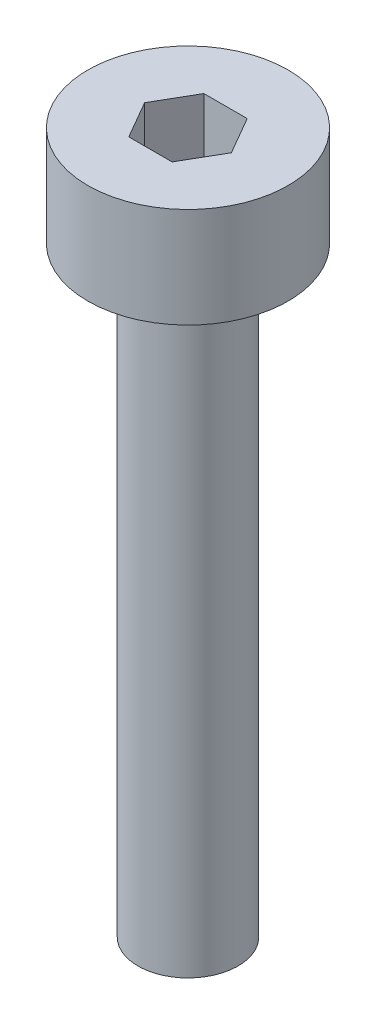
from build123d import *

# Parameters (mm, degrees)
SKETCH_1_R            = 2
EXTRUDE_246_DEPTH     = 2
CUT_EXTRUDE_376_DEPTH = 1.5
SKETCH_3_R            = 1
EXTRUDE_477_DEPTH     = 12


with BuildPart() as part:
    # 草图1 → Extrude 246 (new body)
    with BuildSketch(Plane(origin=(0, 0, 0), x_dir=(1, 0, 0), z_dir=(0, 1, 0))):
        Circle(SKETCH_1_R)
    extrude(amount=EXTRUDE_246_DEPTH)

    # 草图2 → Cut-Extrude 376 (cut)
    with BuildSketch(Plane(origin=(0, 2, 0), x_dir=(1, 0, 0), z_dir=(0, 1, 0))):
        Polygon((0.866025404, 0), (0.433012702, 0.75), (-0.433012702, 0.75), (-0.866025404, 0), (-0.433012702, -0.75), (0.433012702, -0.75), align=None)
    extrude(amount=-CUT_EXTRUDE_376_DEPTH, mode=Mode.SUBTRACT)

    # 草图3 → Extrude 477 (add)
    with BuildSketch(Plane.XZ):
        Circle(SKETCH_3_R)
    extrude(amount=EXTRUDE_477_DEPTH)


solid = part.part
